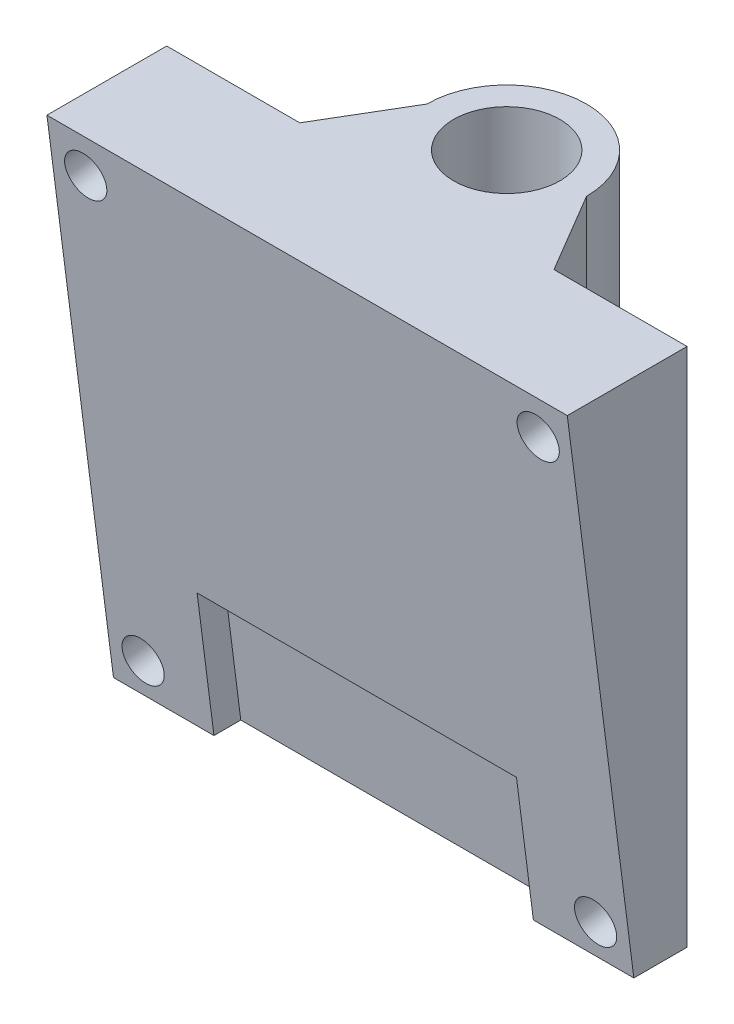
from build123d import *

# Parameters (mm, degrees)
SKETCH_1_R                  = 4
EXTRUDE_1_DEPTH             = 39.1
EXTRUDE_2_DEPTH             = 39.1
HOLE_WIZARD_M32_D           = 3.15
PATTERN_LINEAR_2_COUNT      = 2
PATTERN_LINEAR_2_PITCH      = 34
PATTERN_LINEAR_2_COUNT_DIR2 = 2
PATTERN_LINEAR_2_PITCH_DIR2 = 34
SKETCH_10_W                 = 24
SKETCH_10_H                 = 12
CUT_EXTRUDE_2_DEPTH         = 2


with BuildPart() as part:
    # Эскиз1 → Бобышка-Вытянуть1 (new body)
    with BuildSketch(Plane(origin=(0, 0, 0), x_dir=(1, 0, 0), z_dir=(0, 1, 0))):
        with BuildLine():
            Line((-19.55, -10), (19.55, -10))
            Line((19.55, -10), (19.55, -6))
            Line((19.55, -6), (9.55, -6))
            Line((9.55, -6), (6, 0))
            ThreePointArc((6, 0), (0, 6), (-6, 0))
            Line((-6, 0), (-9.55, -6))
            Line((-9.55, -6), (-19.55, -6))
            Line((-19.55, -6), (-19.55, -10))
        make_face()
        Circle(SKETCH_1_R, mode=Mode.SUBTRACT)
    extrude(amount=EXTRUDE_1_DEPTH)

    # Эскиз5 → Бобышка-Вытянуть2 (add)
    with BuildSketch(Plane(origin=(19.55, 0, 0), x_dir=(0, 0, -1), z_dir=(1, 0, 0))):
        Polygon((-10, 0), (-15, 39.1), (-10, 39.1), align=None)
    extrude(amount=-EXTRUDE_2_DEPTH)

    # Сверло под метчик  спиральное M32 (through all)
    with Locations(Plane(origin=(0, -1.258197592, 9.839105167), x_dir=(1, 0, 0), z_dir=(0, -0.126844327, 0.991922636))):
        with Locations((-17, 3.818443269)):
            hole_wizard_m32 = Hole(HOLE_WIZARD_M32_D / 2)

    # Линейный массив2: Hole Wizard M32 2 × 2
    with Locations(*[Vector(1, 0, 0) * (i * PATTERN_LINEAR_2_PITCH) + Vector(0, 0.991922636, 0.126844327) * (j * PATTERN_LINEAR_2_PITCH_DIR2) for i in range(PATTERN_LINEAR_2_COUNT) for j in range(PATTERN_LINEAR_2_COUNT_DIR2) if (i, j) != (0, 0)]):
        add(hole_wizard_m32, mode=Mode.SUBTRACT)

    # Эскиз10 → Вырез-Вытянуть2 (cut)
    with BuildSketch(Plane(origin=(0, -1.258197592, 9.839105167), x_dir=(1, 0, 0), z_dir=(0, -0.126844327, 0.991922636))):
        with Locations((0, 5.268443269)):
            Rectangle(SKETCH_10_W, SKETCH_10_H)
    extrude(amount=-CUT_EXTRUDE_2_DEPTH, mode=Mode.SUBTRACT)


solid = part.part
